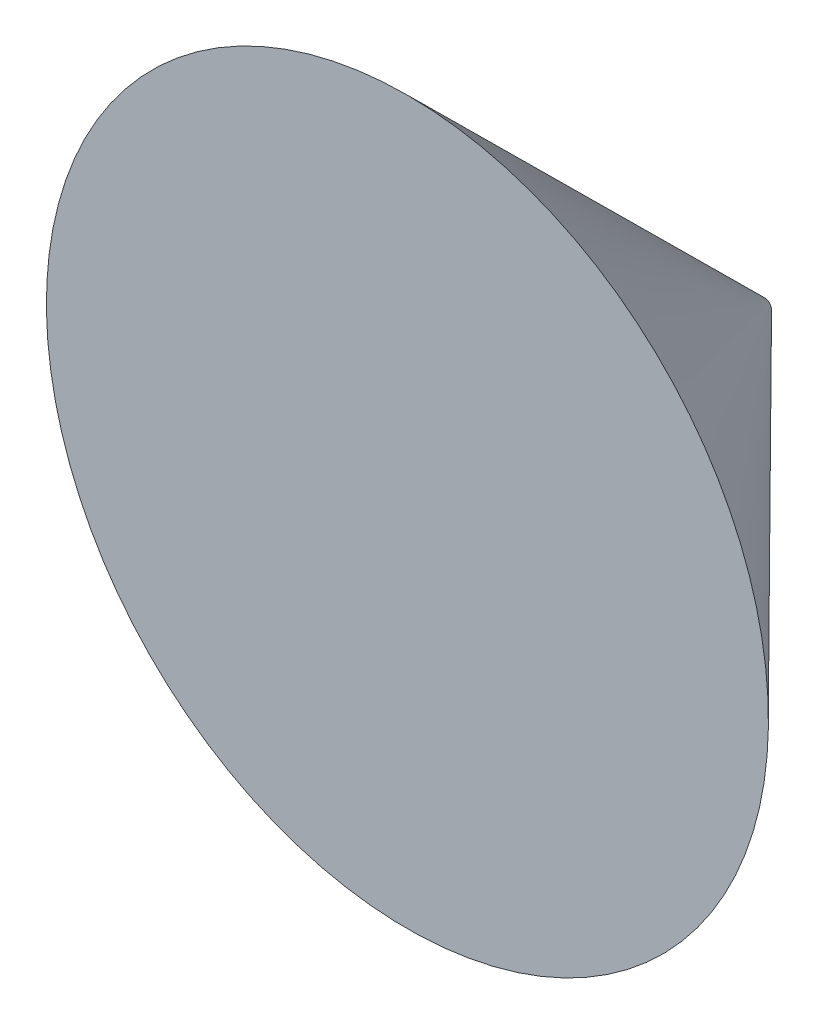
from build123d import *


with BuildPart() as part:
    # Sketch1 → Revolve1 (revolve)
    with BuildSketch(Plane(origin=(0, 0, 0), x_dir=(0, 0, -1), z_dir=(1, 0, 0))):
        Polygon((0, 0), (-196, 0), (-196, 198.296997277), (0, 4), align=None)
    revolve(axis=Axis((0, 0, 0), (0, 0, 1)))


solid = part.part
